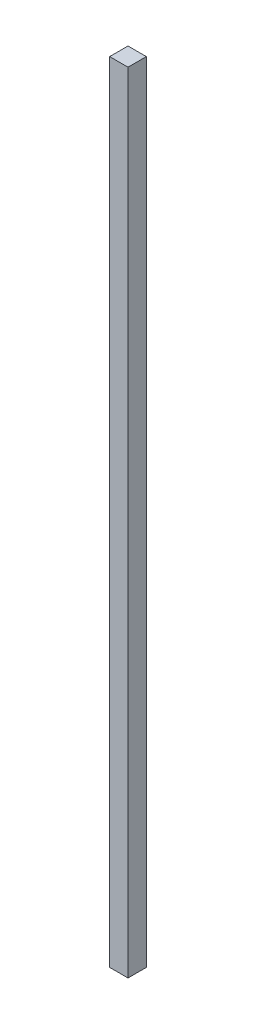
from build123d import *

# Parameters (mm, degrees)
SKETCH1_W           = 25.4
SKETCH1_H           = 25.4
BOSS_EXTRUDE1_DEPTH = 1092.2


with BuildPart() as part:
    # Sketch1 → Boss-Extrude1 (new body)
    with BuildSketch(Plane(origin=(0, 0, 0), x_dir=(1, 0, 0), z_dir=(0, 1, 0))):
        Rectangle(SKETCH1_W, SKETCH1_H)
    extrude(amount=BOSS_EXTRUDE1_DEPTH)


solid = part.part
